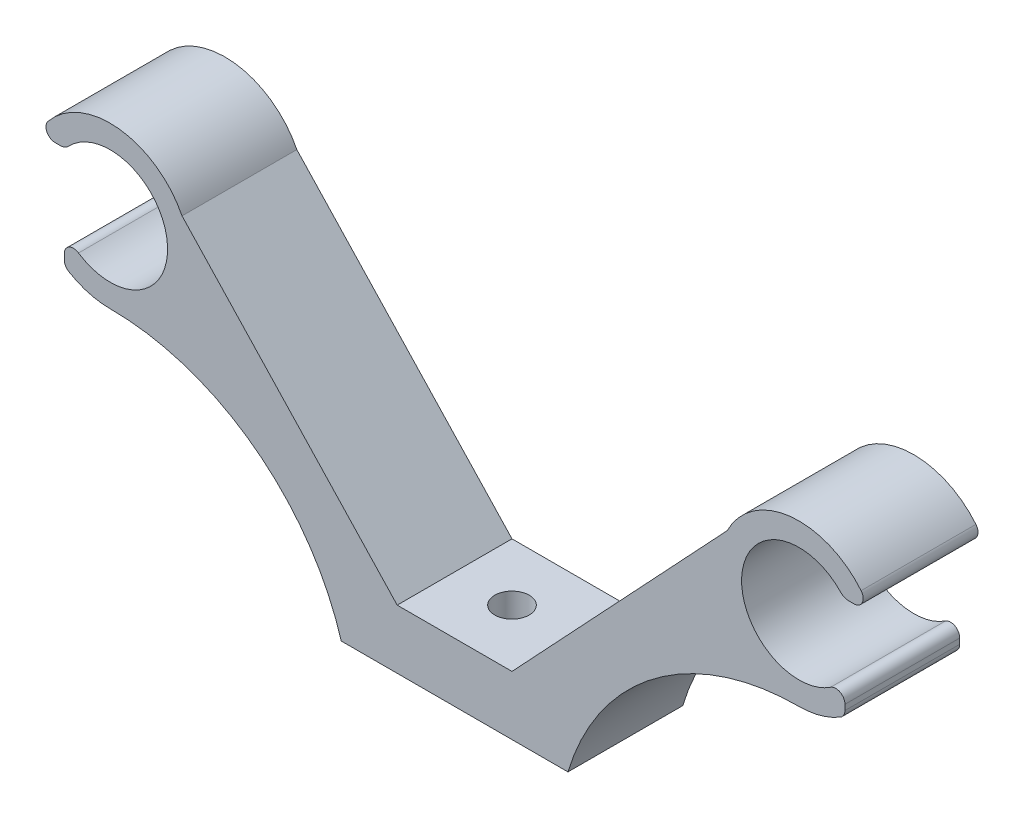
from build123d import *

# Parameters (mm, degrees)
BOSS_EXTRUDE1_DEPTH = 10
SKETCH2_R           = 1.5
CUT_EXTRUDE1_DEPTH  = 10


with BuildPart() as part:
    # Sketch1 → Boss-Extrude1 (new body)
    with BuildSketch(Plane.XY):
        with BuildLine():
            Line((9.875388203, 0), (-9.875388203, 0))
            ThreePointArc((-9.875388203, 0), (-17.450099602, 10.83745824), (-30, 15))
            ThreePointArc((-30, 15), (-31.8749625, 15.255779094), (-33.612903226, 16.004424108))
            ThreePointArc((-33.612903226, 16.004424108), (-33.896535204, 16.29613728), (-34, 16.689632781))
            Line((-34, 16.689632781), (-34, 17.162645351))
            ThreePointArc((-34, 17.162645351), (-33.578745661, 17.867309614), (-32.75862069, 17.829866682))
            ThreePointArc((-32.75862069, 17.829866682), (-25.031925557, 22.564124391), (-33.623370468, 25.445458816))
            ThreePointArc((-33.623370468, 25.445458816), (-33.953767859, 25.215558804), (-34.348044562, 25.134550579))
            Line((-34.348044562, 25.134550579), (-34.791587602, 25.134550579))
            ThreePointArc((-34.791587602, 25.134550579), (-35.51482586, 25.592605522), (-35.409856969, 26.442234524))
            ThreePointArc((-35.409856969, 26.442234524), (-29.220414383, 28.95645357), (-23.74103901, 25.134550579))
            Line((-23.74103901, 25.134550579), (-5, 5.145359938))
            Line((-5, 5.145359938), (5, 5.145359938))
            Line((5, 5.145359938), (23.74103901, 25.134550579))
            ThreePointArc((23.74103901, 25.134550579), (29.220414383, 28.95645357), (35.409856969, 26.442234524))
            ThreePointArc((35.409856969, 26.442234524), (35.51482586, 25.592605522), (34.791587602, 25.134550579))
            Line((34.791587602, 25.134550579), (34.348044562, 25.134550579))
            ThreePointArc((34.348044562, 25.134550579), (33.953767859, 25.215558804), (33.623370468, 25.445458816))
            ThreePointArc((33.623370468, 25.445458816), (25.031925557, 22.564124391), (32.75862069, 17.829866682))
            ThreePointArc((32.75862069, 17.829866682), (33.578745661, 17.867309614), (34, 17.162645351))
            Line((34, 17.162645351), (34, 16.689632781))
            ThreePointArc((34, 16.689632781), (33.896535204, 16.29613728), (33.612903226, 16.004424108))
            ThreePointArc((33.612903226, 16.004424108), (31.8749625, 15.255779094), (30, 15))
            ThreePointArc((30, 15), (17.450099602, 10.83745824), (9.875388203, 0))
        make_face()
    extrude(amount=BOSS_EXTRUDE1_DEPTH)

    # Sketch2 → Cut-Extrude1 (cut)
    with BuildSketch(Plane(origin=(0, 5.145359938, 0), x_dir=(1, 0, 0), z_dir=(0, 1, 0))):
        with Locations((0, -5)):
            Circle(SKETCH2_R)
    extrude(amount=-CUT_EXTRUDE1_DEPTH, mode=Mode.SUBTRACT)


solid = part.part
